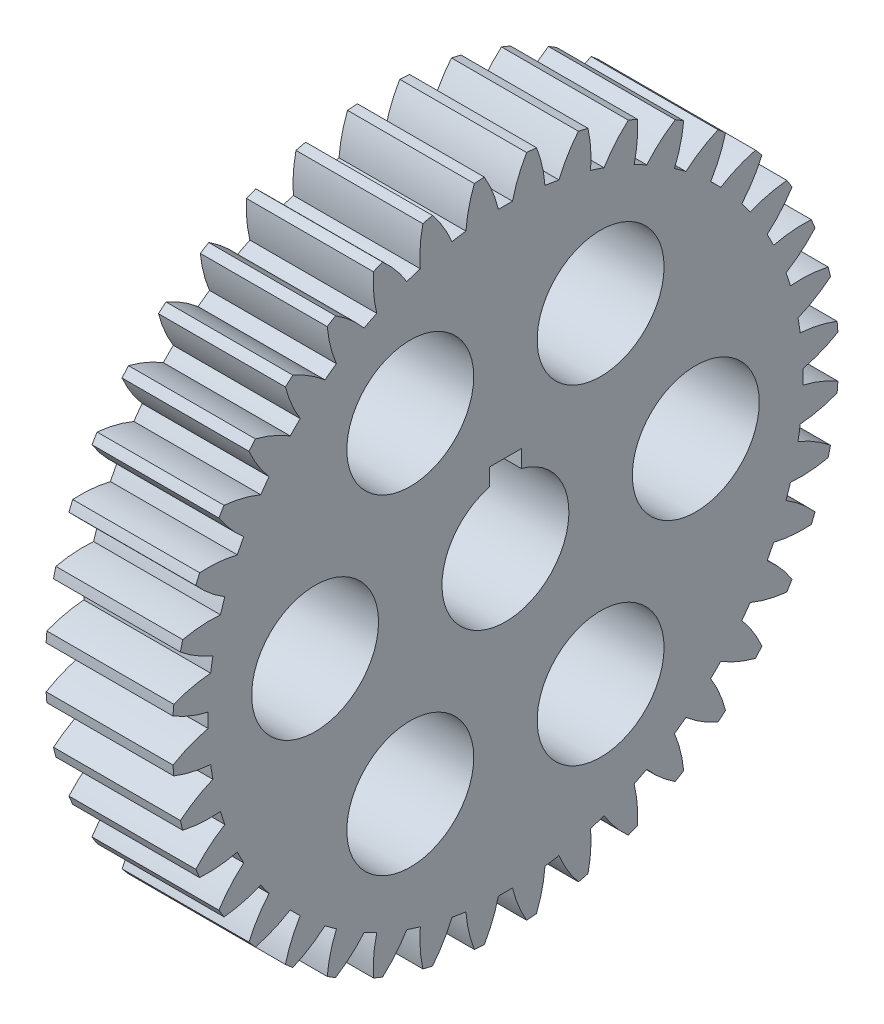
from build123d import *

# Parameters (mm, degrees)
BASPROSKE_W             = 12.7
BASPROSKE_H             = 33.3375
TOOTHCUT_DEPTH          = 49.826916885
TEETHCUTS_COUNT         = 40
TEETHCUTS_ANGLE         = 351
BORSKE_R                = 6.35
BORE_DEPTH              = 50.8000508
KEYSKE_W                = 3.175
KEYSKE_H                = 7.4676
KEYWAY_DEPTH            = 50.8000508
SKETCH1_W               = 3.175
SKETCH1_H               = 0.4064
CUT_EXTRUDE1_DEPTH      = 49.734626122
CUT_EXTRUDE1_DEPTH_BACK = 49.734626122
SKETCH2_R               = 6.35
CUT_EXTRUDE3_DEPTH      = 49.734626122
CIRPATTERN1_COUNT       = 6


with BuildPart() as part:
    # BasProSke → Base-Revolve (revolve)
    with BuildSketch(Plane(origin=(0, 0, 0), x_dir=(1, 0, 0), z_dir=(0, 1, 0)), mode=Mode.PRIVATE) as base_revolve_sk:
        with Locations((6.35, 16.66875)):
            Rectangle(BASPROSKE_W, BASPROSKE_H)
    revolve(base_revolve_sk.sketch.rotate(Axis((-10, 0, 0), (1, 0, 0)), 180), axis=Axis((-10, 0, 0), (1, 0, 0)))

    # TooCutSke → ToothCut (cut, through all)
    with BuildSketch(Plane(origin=(0, 0, 0), x_dir=(0, 0, -1), z_dir=(1, 0, 0))):
        with BuildLine():
            ThreePointArc((0.707133158, 29.755953879), (0, 29.764355), (-0.707133158, 29.755953879))
            ThreePointArc((-0.707133158, 29.755953879), (-1.288040274, 31.579180961), (-2.136281965, 33.294434907))
            ThreePointArc((-2.136281965, 33.294434907), (0, 33.3629), (2.136281965, 33.294434907))
            ThreePointArc((2.136281965, 33.294434907), (1.288040274, 31.579180961), (0.707133158, 29.755953879))
        make_face()
    toothcut = extrude(amount=TOOTHCUT_DEPTH, mode=Mode.SUBTRACT)

    # TeethCuts: ToothCut ×40 about axis
    teethcuts_axis = Axis((-10, 0, 0), (1, 0, 0))
    for i in range(1, TEETHCUTS_COUNT):
        add(toothcut.rotate(teethcuts_axis, i * TEETHCUTS_ANGLE / (TEETHCUTS_COUNT - 1)), mode=Mode.SUBTRACT)

    # BorSke → Bore (cut, symmetric)
    with BuildSketch(Plane(origin=(0, 0, 0), x_dir=(0, 0, -1), z_dir=(1, 0, 0))):
        with Locations(Location((0, 0, 0), (0, 0, 180))):
            Circle(BORSKE_R)
    extrude(amount=BORE_DEPTH, both=True, mode=Mode.SUBTRACT)

    # KeySke → Keyway (cut, symmetric)
    with BuildSketch(Plane(origin=(0, 0, 0), x_dir=(0, 0, -1), z_dir=(1, 0, 0))):
        with Locations((0, 3.7338)):
            Rectangle(KEYSKE_W, KEYSKE_H)
    extrude(amount=KEYWAY_DEPTH, both=True, mode=Mode.SUBTRACT)

    # Sketch1 → Cut-Extrude1 (cut, two sides)
    with BuildSketch(Plane(origin=(12.7, 0, 0), x_dir=(0, 0, -1), z_dir=(1, 0, 0))) as cut_extrude1_sk:
        with Locations((0, 7.6708)):
            Rectangle(SKETCH1_W, SKETCH1_H)
    extrude(amount=CUT_EXTRUDE1_DEPTH, mode=Mode.SUBTRACT)
    extrude(cut_extrude1_sk.sketch, amount=-CUT_EXTRUDE1_DEPTH_BACK, mode=Mode.SUBTRACT)

    # Sketch2 → Cut-Extrude3 (cut, through all)
    with BuildSketch(Plane(origin=(12.7, 0, 0), x_dir=(0, 0, -1), z_dir=(1, 0, 0))):
        with Locations((-19.05, 0)):
            Circle(SKETCH2_R)
    cut_extrude3 = extrude(amount=-CUT_EXTRUDE3_DEPTH, mode=Mode.SUBTRACT)

    # CirPattern1: Cut-Extrude3 ×6 about axis
    cirpattern1_axis = Axis((0, 0, 0), (1, 0, 0))
    for i in range(1, CIRPATTERN1_COUNT):
        add(cut_extrude3.rotate(cirpattern1_axis, i * 360 / CIRPATTERN1_COUNT), mode=Mode.SUBTRACT)


solid = part.part
